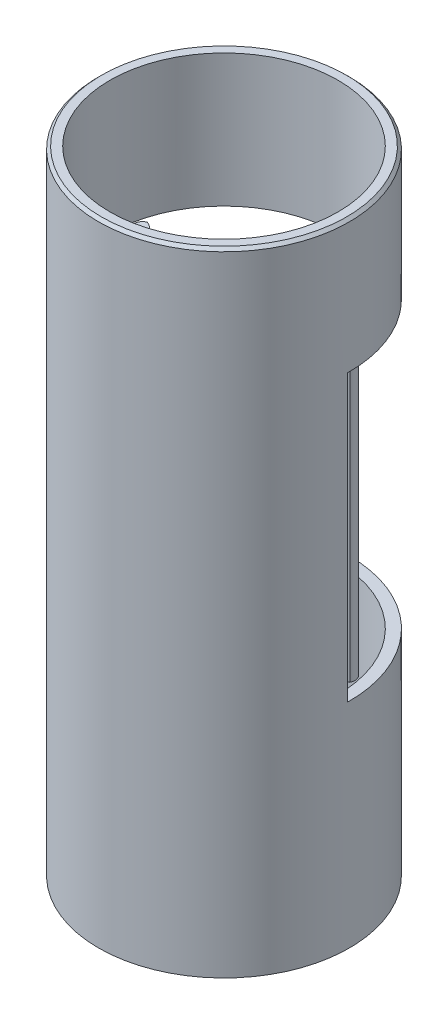
from build123d import *

# Parameters (mm, degrees)
SKETCH1_R           = 17.6
SKETCH1_R_2         = 16
BOSS_EXTRUDE1_DEPTH = 18.6
BOSS_EXTRUDE4_DEPTH = 40
FILLET1_R           = 3
SKETCH3_R           = 17.6
SKETCH3_R_2         = 16
BOSS_EXTRUDE5_DEPTH = 30
CHAMFER1_SIZE       = 0.4


with BuildPart() as part:
    # Sketch1 → Boss-Extrude1 (new body)
    with BuildSketch(Plane(origin=(0, 0, 0), x_dir=(1, 0, 0), z_dir=(0, 1, 0))):
        Circle(SKETCH1_R)
        Circle(SKETCH1_R_2, mode=Mode.SUBTRACT)
    extrude(amount=BOSS_EXTRUDE1_DEPTH)

    # Sketch2 → Boss-Extrude4 (add)
    with BuildSketch(Plane.XZ):
        with BuildLine():
            Line((-17.597442996, 0.3), (-15.997187253, 0.3))
            ThreePointArc((-15.997187253, 0.3), (-14.633011589, -0.743357507), (-15.358569497, -2.3))
            ThreePointArc((-15.358569497, -2.3), (-15.42406436, -3.285276346), (-14.728427881, -3.986096541))
            ThreePointArc((-14.728427881, -3.986096541), (-12.8509861, -0.489844124), (-15.86226693, 2.094871792))
            ThreePointArc((-15.86226693, 2.094871792), (0, 16), (15.86226693, 2.094871792))
            ThreePointArc((15.86226693, 2.094871792), (12.8509861, -0.489844124), (14.728427881, -3.986096541))
            ThreePointArc((14.728427881, -3.986096541), (15.42406436, -3.285276346), (15.358569497, -2.3))
            ThreePointArc((15.358569497, -2.3), (14.633011589, -0.743357507), (15.997187253, 0.3))
            Line((15.997187253, 0.3), (17.597442996, 0.3))
            ThreePointArc((17.597442996, 0.3), (0, 17.6), (-17.597442996, 0.3))
        make_face()
    extrude(amount=BOSS_EXTRUDE4_DEPTH)

    # Fillet1
    fillet1_edges = [part.edges().sort_by_distance(p)[0] for p in [
        (-15.86226693, -20, 2.094871792),
        (15.86226693, -20, 2.094871792),
    ]]
    fillet(fillet1_edges, radius=FILLET1_R)

    # Sketch3 → Boss-Extrude5 (add)
    with BuildSketch(Plane.XZ.offset(40)):
        Circle(SKETCH3_R)
        Circle(SKETCH3_R_2, mode=Mode.SUBTRACT)
    extrude(amount=BOSS_EXTRUDE5_DEPTH)

    # Chamfer1
    chamfer1_edges = [part.edges().sort_by_distance(p)[0] for p in [
        (-17.6, 18.6, 0),
    ]]
    chamfer(chamfer1_edges, length=CHAMFER1_SIZE)


solid = part.part
